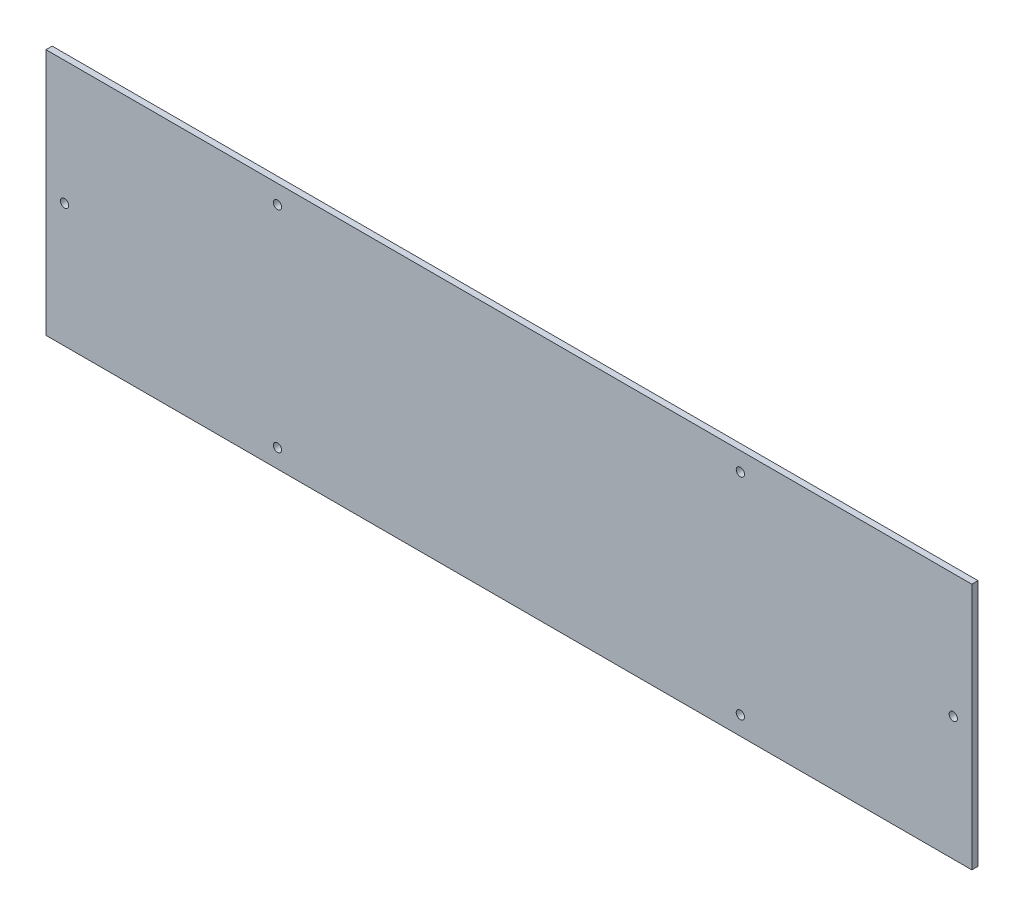
from build123d import *

# Parameters (mm, degrees)
SCHIZZO1_W                   = 449
SCHIZZO1_H                   = 120
SCHIZZO1_R                   = 2
ESTRUSIONE_ESTRUSIONE1_DEPTH = 3


with BuildPart() as part:
    # Schizzo1 → Estrusione-Estrusione1 (new body)
    with BuildSketch(Plane.XY):
        with Locations((224.5, 60)):
            Rectangle(SCHIZZO1_W, SCHIZZO1_H)
        with Locations((9, 60)):
            Circle(SCHIZZO1_R, mode=Mode.SUBTRACT)
        with Locations((440, 60)):
            Circle(SCHIZZO1_R, mode=Mode.SUBTRACT)
        with Locations((112.25, 111)):
            Circle(SCHIZZO1_R, mode=Mode.SUBTRACT)
        with Locations((336.75, 111)):
            Circle(SCHIZZO1_R, mode=Mode.SUBTRACT)
        with Locations((336.75, 9)):
            Circle(SCHIZZO1_R, mode=Mode.SUBTRACT)
        with Locations((112.25, 9)):
            Circle(SCHIZZO1_R, mode=Mode.SUBTRACT)
    extrude(amount=ESTRUSIONE_ESTRUSIONE1_DEPTH)


solid = part.part
